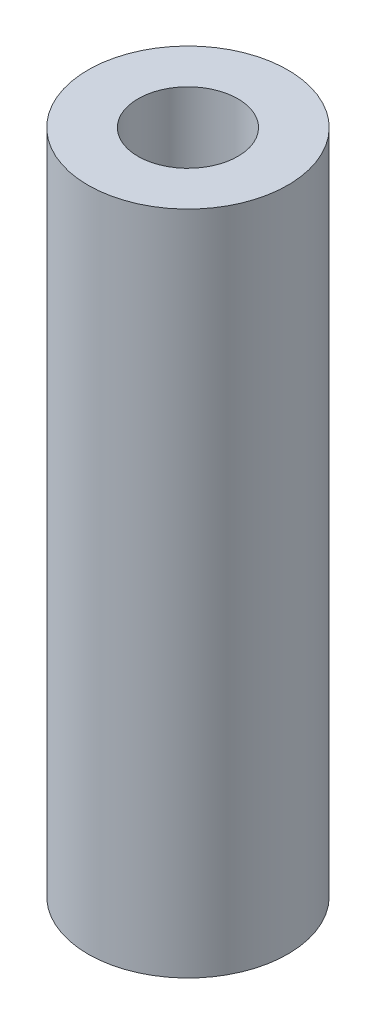
from build123d import *

# Parameters (mm, degrees)
SKETCH1_R           = 3
SKETCH1_R_2         = 1.5
BOSS_EXTRUDE1_DEPTH = 20


with BuildPart() as part:
    # Sketch1 → Boss-Extrude1 (new body)
    with BuildSketch(Plane(origin=(0, 0, 0), x_dir=(1, 0, 0), z_dir=(0, 1, 0))):
        Circle(SKETCH1_R)
        Circle(SKETCH1_R_2, mode=Mode.SUBTRACT)
    extrude(amount=BOSS_EXTRUDE1_DEPTH)


solid = part.part
